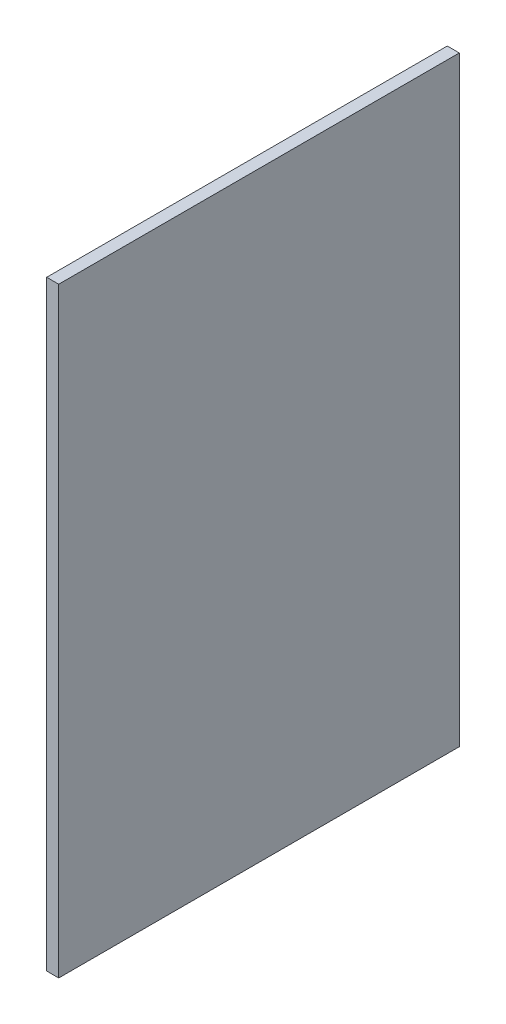
from build123d import *

# Parameters (mm, degrees)
SKETCH_1_W      = 600
SKETCH_1_H      = 900
EXTRUDE_1_DEPTH = 18


with BuildPart() as part:
    # Эскиз1 → Бобышка-Вытянуть1 (new body)
    with BuildSketch(Plane(origin=(0, 0, 0), x_dir=(0, 0, -1), z_dir=(1, 0, 0))):
        with Locations((300, 450)):
            Rectangle(SKETCH_1_W, SKETCH_1_H)
    extrude(amount=EXTRUDE_1_DEPTH)


solid = part.part
